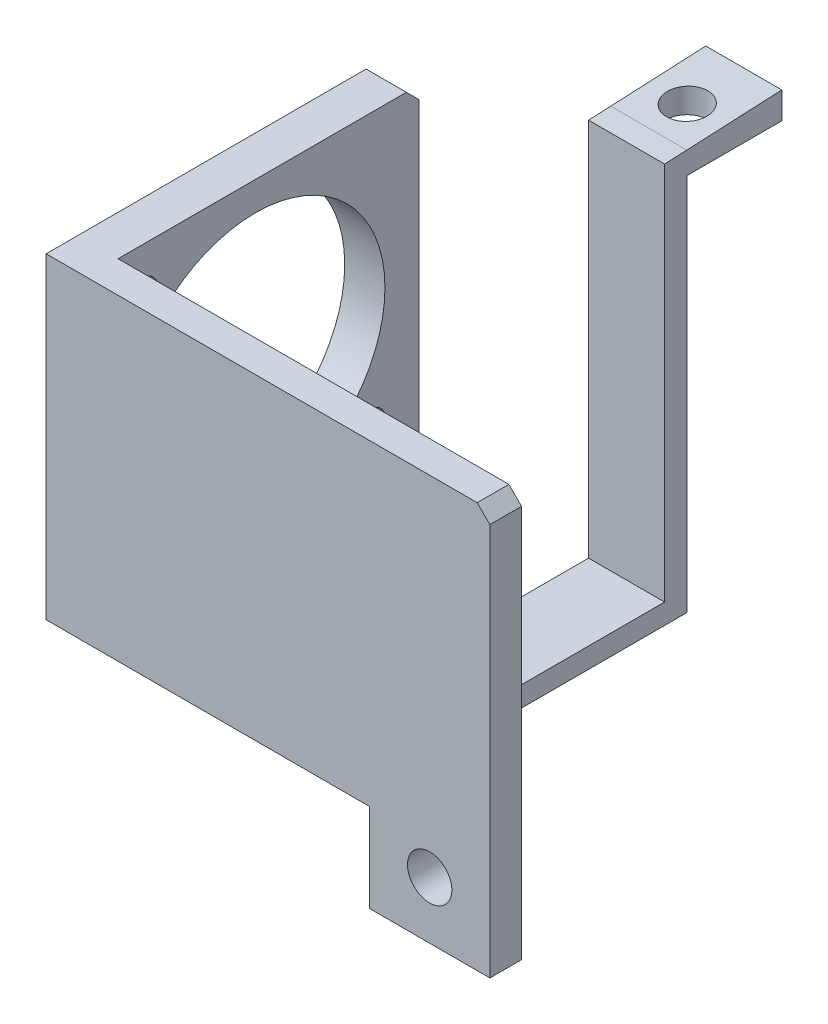
from build123d import *

# Parameters (mm, degrees)
BOSS_EXTRUDE1_DEPTH  = 5
SKETCH2_W            = 6.35
SKETCH2_H            = 50
BOSS_EXTRUDE2_DEPTH  = 52.48
CUT_EXTRUDE1_REACH   = 106.448
SKETCH3_R            = 20.44
SKETCH3_R_2          = 2.555
SKETCH3_W            = 5
SKETCH3_H            = 50
CUT_EXTRUDE2_REACH   = 108.104
SKETCH4_R            = 3.5
CUT_EXTRUDE6_REACH   = 108.104
SKETCH14_W           = 23.196263878
SKETCH14_H           = 15.316152196
SKETCH15_W           = 12
SKETCH15_H           = 3.2
BOSS_EXTRUDE7_DEPTH  = 46.5
BOSS_EXTRUDE8_REACH  = 98.667
SKETCH16_W           = 12
SKETCH16_H           = 3.5
SKETCH17_W           = 12
SKETCH17_H           = 3.5
BOSS_EXTRUDE9_DEPTH  = 15
CHAMFER2_SIZE        = 2
SKETCH22_W           = 12
SKETCH22_H           = 15
BOSS_EXTRUDE10_DEPTH = 0.72
CUT_EXTRUDE8_REACH   = 103.606
CUT_EXTRUDE7_REACH   = 120.762
SKETCH18_R           = 3.25


with BuildPart() as part:
    # Sketch1 → Boss-Extrude1 (new body)
    with BuildSketch(Plane.XY):
        Polygon((0, 0), (0, 50), (51, 50), (51, 64.061014889), (70, 64.061014889), (70, -13.938985111), (51, -13.938985111), (51, 0), align=None)
    extrude(amount=BOSS_EXTRUDE1_DEPTH)

    # Sketch2 → Boss-Extrude2 (add)
    with BuildSketch(Plane(origin=(0, 0, 0), x_dir=(-1, 0, 0), z_dir=(0, 0, -1))):
        with Locations((-3.175, 25)):
            Rectangle(SKETCH2_W, SKETCH2_H)
    extrude(amount=BOSS_EXTRUDE2_DEPTH)

    # Sketch3 → Cut-Extrude1 (cut, up to next)
    with BuildSketch(Plane(origin=(6.35, 0, 0), x_dir=(0, 0, -1), z_dir=(1, 0, 0)), mode=Mode.PRIVATE) as cut_extrude1_sk1:
        with Locations((21.66, 25)):
            Circle(SKETCH3_R)
    cut_extrude1_tool1 = extrude(cut_extrude1_sk1.sketch, amount=-CUT_EXTRUDE1_REACH, mode=Mode.PRIVATE) & part.part
    # Sketch3 → Cut-Extrude1 (cut, up to next)
    with BuildSketch(Plane(origin=(6.35, 0, 0), x_dir=(0, 0, -1), z_dir=(1, 0, 0)), mode=Mode.PRIVATE) as cut_extrude1_sk2:
        with Locations((3.695, 42.955)):
            Circle(SKETCH3_R_2)
    cut_extrude1_tool2 = extrude(cut_extrude1_sk2.sketch, amount=-CUT_EXTRUDE1_REACH, mode=Mode.PRIVATE) & part.part
    # Sketch3 → Cut-Extrude1 (cut, up to next)
    with BuildSketch(Plane(origin=(6.35, 0, 0), x_dir=(0, 0, -1), z_dir=(1, 0, 0)), mode=Mode.PRIVATE) as cut_extrude1_sk3:
        with Locations((39.615, 7.045)):
            Circle(SKETCH3_R_2)
    cut_extrude1_tool3 = extrude(cut_extrude1_sk3.sketch, amount=-CUT_EXTRUDE1_REACH, mode=Mode.PRIVATE) & part.part
    # Sketch3 → Cut-Extrude1 (cut, up to next)
    with BuildSketch(Plane(origin=(6.35, 0, 0), x_dir=(0, 0, -1), z_dir=(1, 0, 0)), mode=Mode.PRIVATE) as cut_extrude1_sk4:
        with Locations((49.98, 25)):
            Rectangle(SKETCH3_W, SKETCH3_H)
    cut_extrude1_tool4 = extrude(cut_extrude1_sk4.sketch, amount=-CUT_EXTRUDE1_REACH, mode=Mode.PRIVATE) & part.part
    add(cut_extrude1_tool1.solids().sort_by_distance((6.35, 25, -21.66))[0], mode=Mode.SUBTRACT)
    add(cut_extrude1_tool2.solids().sort_by_distance((6.35, 42.955, -3.695))[0], mode=Mode.SUBTRACT)
    add(cut_extrude1_tool3.solids().sort_by_distance((6.35, 7.045, -39.615))[0], mode=Mode.SUBTRACT)
    add(cut_extrude1_tool4.solids().sort_by_distance((6.35, 25, -49.98))[0], mode=Mode.SUBTRACT)

    # Sketch4 → Cut-Extrude2 (cut, up to next)
    with BuildSketch(Plane(origin=(0, 0, 0), x_dir=(-1, 0, 0), z_dir=(0, 0, -1)), mode=Mode.PRIVATE) as cut_extrude2_sk1:
        with Locations((-60.5, 55.061014889)):
            Circle(SKETCH4_R)
    cut_extrude2_tool1 = extrude(cut_extrude2_sk1.sketch, amount=-CUT_EXTRUDE2_REACH, mode=Mode.PRIVATE) & part.part
    # Sketch4 → Cut-Extrude2 (cut, up to next)
    with BuildSketch(Plane(origin=(0, 0, 0), x_dir=(-1, 0, 0), z_dir=(0, 0, -1)), mode=Mode.PRIVATE) as cut_extrude2_sk2:
        with Locations((-60.5, -4.938985111)):
            Circle(SKETCH4_R)
    cut_extrude2_tool2 = extrude(cut_extrude2_sk2.sketch, amount=-CUT_EXTRUDE2_REACH, mode=Mode.PRIVATE) & part.part
    add(cut_extrude2_tool1.solids().sort_by_distance((60.5, 55.061015, 0))[0], mode=Mode.SUBTRACT)
    add(cut_extrude2_tool2.solids().sort_by_distance((60.5, -4.938985, 0))[0], mode=Mode.SUBTRACT)

    # Sketch14 → Cut-Extrude6 (cut, up to next)
    with BuildSketch(Plane(origin=(0, 0, 0), x_dir=(-1, 0, 0), z_dir=(0, 0, -1)), mode=Mode.PRIVATE) as cut_extrude6_sk1:
        with Locations((-62.598131939, 57.658076098)):
            Rectangle(SKETCH14_W, SKETCH14_H)
    cut_extrude6_tool1 = extrude(cut_extrude6_sk1.sketch, amount=-CUT_EXTRUDE6_REACH, mode=Mode.PRIVATE) & part.part
    add(cut_extrude6_tool1.solids().sort_by_distance((62.598132, 57.658076, 0))[0], mode=Mode.SUBTRACT)

    # Sketch15 → Boss-Extrude7 (add)
    with BuildSketch(Plane(origin=(0, 0, 0), x_dir=(-1, 0, 0), z_dir=(0, 0, -1))):
        with Locations((-43.56, 1.6)):
            Rectangle(SKETCH15_W, SKETCH15_H)
    extrude(amount=BOSS_EXTRUDE7_DEPTH)

    # Boss-Extrude8: up to this plane
    boss_extrude8_end = Plane(origin=(166.832994776, 64.085435133, -66.619565524), z_dir=(-1.1416993347548052e-15, 0.9990256874715413, 0.04413247978546202))
    # Sketch16 → Boss-Extrude8 (add, up to the surface)
    with BuildSketch(Plane(origin=(0, 3.2, 0), x_dir=(1, 0, 0), z_dir=(0, 1, 0)), mode=Mode.PRIVATE) as boss_extrude8_sk1:
        with Locations((43.56, 44.75)):
            Rectangle(SKETCH16_W, SKETCH16_H)
    boss_extrude8_tool1 = split(extrude(boss_extrude8_sk1.sketch, amount=BOSS_EXTRUDE8_REACH, mode=Mode.PRIVATE), bisect_by=boss_extrude8_end, keep=Keep.BOTH, mode=Mode.PRIVATE)
    add(boss_extrude8_tool1.solids().sort_by_distance((43.56, 3.2, -44.75))[0])

    # Sketch17 → Boss-Extrude9 (add)
    with BuildSketch(Plane(origin=(0, 0, -46.5), x_dir=(-1, 0, 0), z_dir=(0, 0, -1))):
        with Locations((-43.56, 61.446642853)):
            Rectangle(SKETCH17_W, SKETCH17_H)
    extrude(amount=BOSS_EXTRUDE9_DEPTH)

    # Chamfer2
    chamfer2_edges = [part.edges().sort_by_distance(p)[0] for p in [
        (3.175, 0, -47.48),
        (3.175, 50, -47.48),
        (70, 50, 2.5),
    ]]
    chamfer(chamfer2_edges, length=CHAMFER2_SIZE)

    # Sketch22 → Boss-Extrude10 (add)
    with BuildSketch(Plane(origin=(0, 63.196642853, 0), x_dir=(1, 0, 0), z_dir=(0, 1, 0))):
        with Locations((43.56, 54)):
            Rectangle(SKETCH22_W, SKETCH22_H)
    extrude(amount=BOSS_EXTRUDE10_DEPTH)

    # Sketch23 → Cut-Extrude8 (cut, up to next)
    with BuildSketch(Plane(origin=(49.56, 0, 0), x_dir=(0, 0, -1), z_dir=(1, 0, 0)), mode=Mode.PRIVATE) as cut_extrude8_sk1:
        Polygon((46.5, 63.916642853), (46.5, 63.196642853), (61.5, 63.916642853), align=None)
    cut_extrude8_tool1 = extrude(cut_extrude8_sk1.sketch, amount=-CUT_EXTRUDE8_REACH, mode=Mode.PRIVATE) & part.part
    add(cut_extrude8_tool1.solids().sort_by_distance((49.56, 63.676643, -51.5))[0], mode=Mode.SUBTRACT)

    # Cut-Extrude7: up to this plane
    cut_extrude7_end = Plane(origin=(-0.001, 63.196642853, -46.5), z_dir=(-2.1659106514416256e-15, -0.9988499868416298, -0.04794479936839813))
    # Sketch18 → Cut-Extrude7 (cut, up to the surface)
    with BuildSketch(Plane.XZ.offset(-59.696642853), mode=Mode.PRIVATE) as cut_extrude7_sk1:
        with Locations(Location((43.56, -52.57, 0), (0, 0, 270))):
            Circle(SKETCH18_R)
    cut_extrude7_tool1 = split(extrude(cut_extrude7_sk1.sketch, amount=-CUT_EXTRUDE7_REACH, mode=Mode.PRIVATE), bisect_by=cut_extrude7_end, keep=Keep.BOTH, mode=Mode.PRIVATE)
    add(cut_extrude7_tool1.solids().sort_by_distance((43.56, 59.696643, -52.57))[0], mode=Mode.SUBTRACT)


solid = part.part
